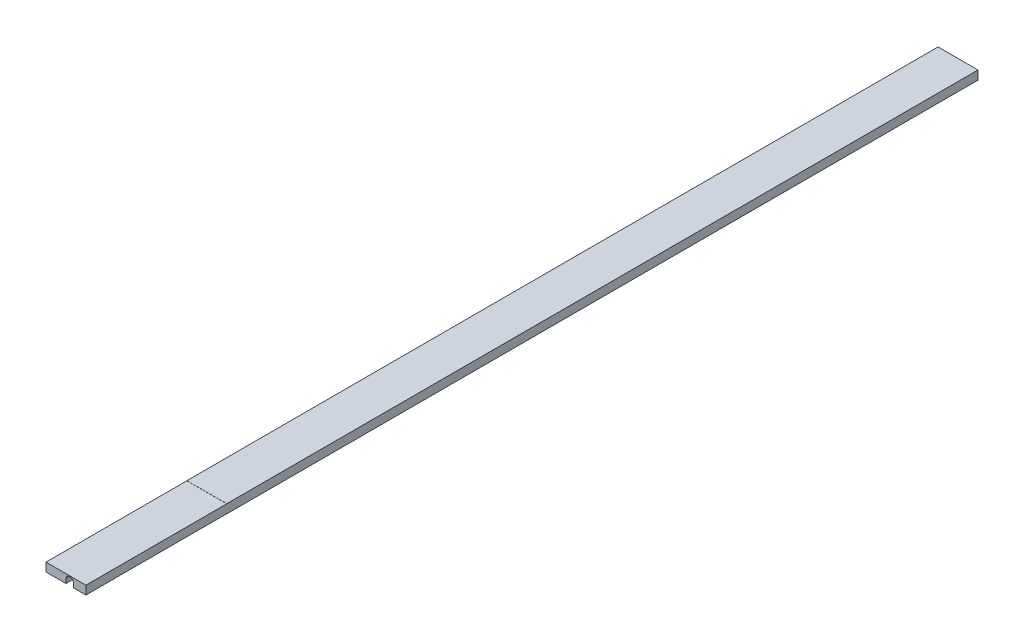
from build123d import *

# Parameters (mm, degrees)
SKETCH1_W           = 25
SKETCH1_H           = 5.5
EXTRUDE1_DEPTH      = 259.4
SKETCH6_W           = 25
SKETCH6_H           = 20
BOSS_EXTRUDE2_DEPTH = 5.5
CUT_EXTRUDE2_DEPTH  = 559.8
SKETCH8_W           = 88.25
SKETCH8_H           = 0.06858
CUT_EXTRUDE3_DEPTH  = 26


with BuildPart() as part:
    # Sketch1 → Extrude1 (new body, symmetric)
    with BuildSketch(Plane.XY):
        Rectangle(SKETCH1_W, SKETCH1_H)
    extrude(amount=EXTRUDE1_DEPTH, both=True)

    # Sketch6 → Boss-Extrude2 (add)
    with BuildSketch(Plane(origin=(0, 2.75, 0), x_dir=(1, 0, 0), z_dir=(0, 1, 0))):
        with Locations((0, 269.4)):
            Rectangle(SKETCH6_W, SKETCH6_H)
        with Locations((0, -269.4)):
            Rectangle(SKETCH6_W, SKETCH6_H)
    extrude(amount=-BOSS_EXTRUDE2_DEPTH)

    # Sketch7 → Cut-Extrude2 (cut, through all)
    with BuildSketch(Plane.XY.offset(279.4)):
        with BuildLine():
            Line((-0.00025, -0.1278), (-0.00025, -2.75))
            Line((-0.00025, -2.75), (4.76225, -2.75))
            Line((4.76225, -2.75), (4.76225, -0.1278))
            ThreePointArc((4.76225, -0.1278), (2.381, 2.25345), (-0.00025, -0.1278))
        make_face()
    extrude(amount=-CUT_EXTRUDE2_DEPTH, mode=Mode.SUBTRACT)

    # Sketch8 → Cut-Extrude3 (cut, through all)
    with BuildSketch(Plane.ZY.offset(12.5)):
        with Locations((235.275, 2.71571)):
            Rectangle(SKETCH8_W, SKETCH8_H)
        with Locations((235.275, -2.71571)):
            Rectangle(SKETCH8_W, SKETCH8_H)
    extrude(amount=-CUT_EXTRUDE3_DEPTH, mode=Mode.SUBTRACT)


solid = part.part
